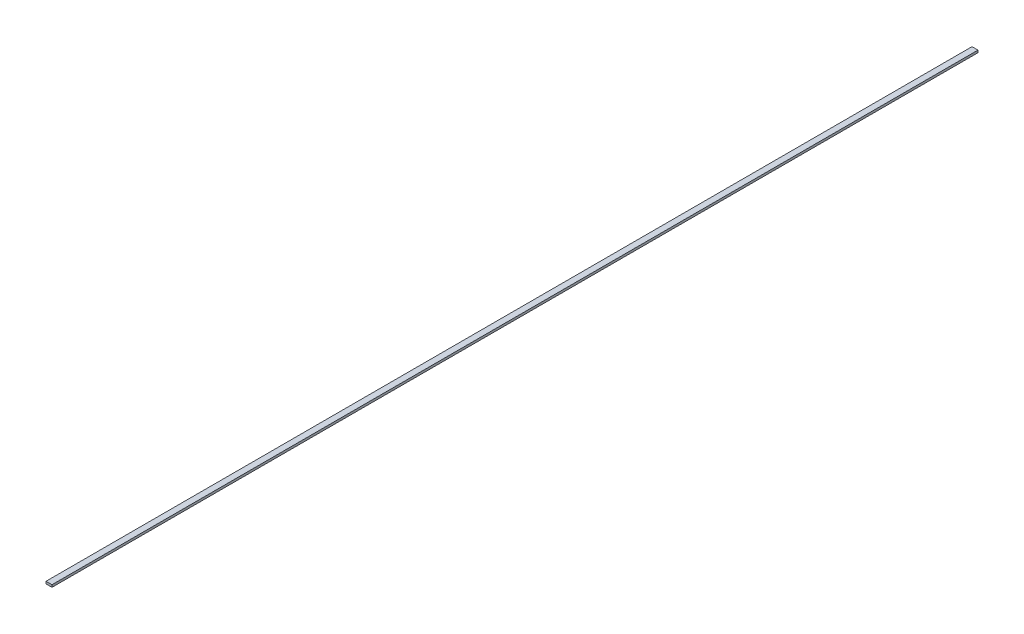
from build123d import *

# Parameters (mm, degrees)
SKETCH1_W      = 0.13
SKETCH1_H      = 20.185
EXTRUDE1_DEPTH = 0.05


with BuildPart() as part:
    # Sketch1 → Extrude1 (new body)
    with BuildSketch(Plane(origin=(0, 0, 0), x_dir=(1, 0, 0), z_dir=(0, 1, 0))):
        Rectangle(SKETCH1_W, SKETCH1_H)
    extrude(amount=EXTRUDE1_DEPTH)


solid = part.part
